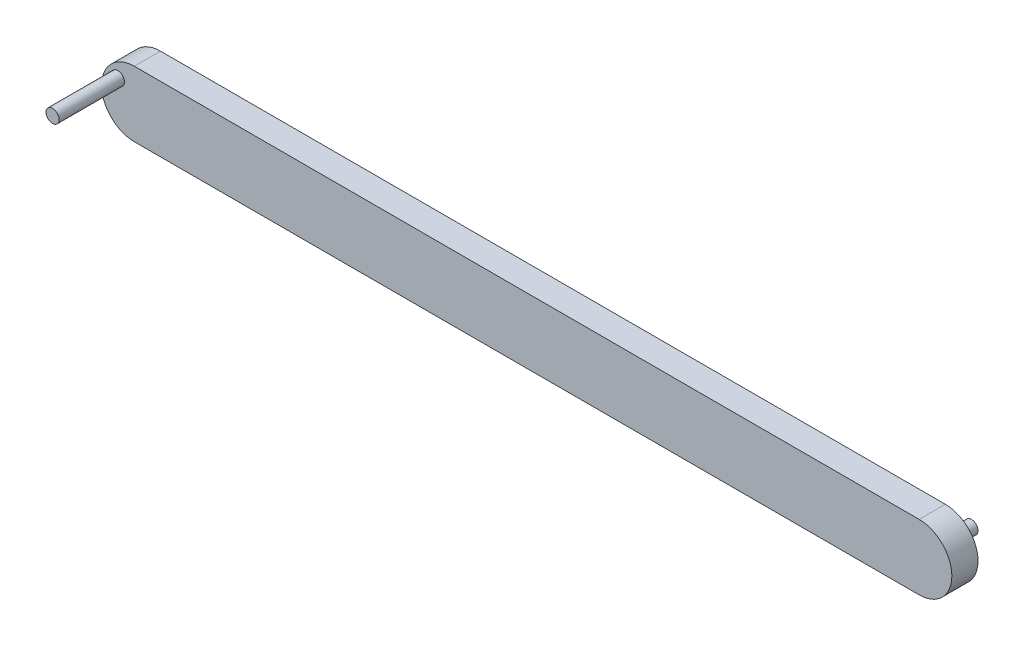
from build123d import *

# Parameters (mm, degrees)
BOSS_EXTRUDE1_DEPTH = 2
SKETCH2_R           = 0.5
BOSS_EXTRUDE2_DEPTH = 2
SKETCH3_R           = 0.5
BOSS_EXTRUDE3_DEPTH = 5


with BuildPart() as part:
    # Sketch1 → Boss-Extrude1 (new body)
    with BuildSketch(Plane.XY):
        with BuildLine():
            Line((-30, 0), (30, 0))
            ThreePointArc((30, 0), (32.5, -2.5), (30, -5))
            Line((30, -5), (-30, -5))
            ThreePointArc((-30, -5), (-32.5, -2.5), (-30, 0))
        make_face()
    extrude(amount=BOSS_EXTRUDE1_DEPTH)

    # Sketch2 → Boss-Extrude2 (add)
    with BuildSketch(Plane(origin=(0, 0, 0), x_dir=(-1, 0, 0), z_dir=(0, 0, -1))):
        with Locations((-30, -2.5)):
            Circle(SKETCH2_R)
    extrude(amount=BOSS_EXTRUDE2_DEPTH)

    # Sketch3 → Boss-Extrude3 (add)
    with BuildSketch(Plane.XY.offset(2)):
        with Locations((-31.251389827, -1.413693431)):
            Circle(SKETCH3_R)
    extrude(amount=BOSS_EXTRUDE3_DEPTH)


solid = part.part
